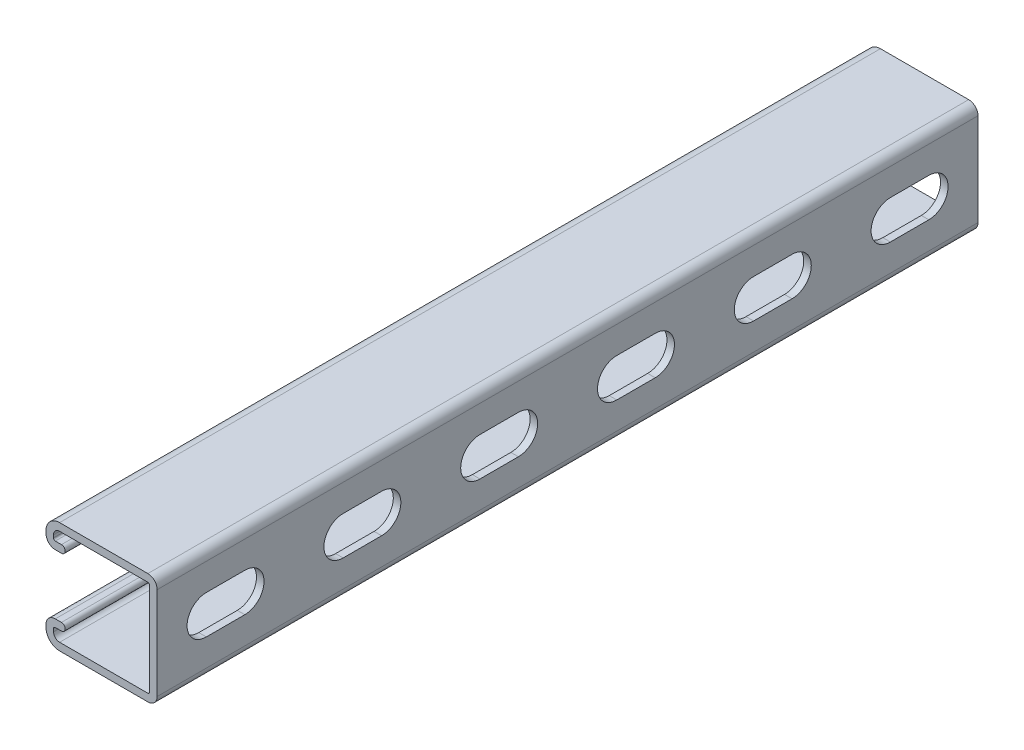
from build123d import *

# Parameters (mm, degrees)
BOSS_EXTRUDE1_DEPTH = 304.8
CUT_EXTRUDE1_DEPTH  = 2.794
LPATTERN1_COUNT     = 6
LPATTERN1_PITCH     = 50.8


with BuildPart() as part:
    # Sketch1 → Boss-Extrude1 (new body)
    with BuildSketch(Plane.XY):
        with BuildLine():
            Line((-36.22675, 20.6375), (-3.46075, 20.6375))
            ThreePointArc((-3.46075, 20.6375), (-1.013630207, 19.623869793), (0, 17.17675))
            Line((0, 17.17675), (0, -17.17675))
            ThreePointArc((0, -17.17675), (-1.013630207, -19.623869793), (-3.46075, -20.6375))
            Line((-3.46075, -20.6375), (-36.22675, -20.6375))
            ThreePointArc((-36.22675, -20.6375), (-39.796401808, -19.158901808), (-41.275, -15.58925))
            Line((-41.275, -15.58925), (-41.275, -14.57325))
            ThreePointArc((-41.275, -14.57325), (-40.261369793, -12.126130207), (-37.81425, -11.1125))
            Line((-37.81425, -11.1125), (-35.5346, -11.1125))
            ThreePointArc((-35.5346, -11.1125), (-34.1376, -12.5095), (-35.5346, -13.9065))
            Line((-35.5346, -13.9065), (-37.81425, -13.9065))
            ThreePointArc((-37.81425, -13.9065), (-38.285713446, -14.101786554), (-38.481, -14.57325))
            Line((-38.481, -14.57325), (-38.481, -15.58925))
            ThreePointArc((-38.481, -15.58925), (-37.820745461, -17.183245461), (-36.22675, -17.8435))
            Line((-36.22675, -17.8435), (-3.46075, -17.8435))
            ThreePointArc((-3.46075, -17.8435), (-2.989286554, -17.648213446), (-2.794, -17.17675))
            Line((-2.794, -17.17675), (-2.794, 17.17675))
            ThreePointArc((-2.794, 17.17675), (-2.989286554, 17.648213446), (-3.46075, 17.8435))
            Line((-3.46075, 17.8435), (-36.22675, 17.8435))
            ThreePointArc((-36.22675, 17.8435), (-37.820745461, 17.183245461), (-38.481, 15.58925))
            Line((-38.481, 15.58925), (-38.481, 14.57325))
            ThreePointArc((-38.481, 14.57325), (-38.285713446, 14.101786554), (-37.81425, 13.9065))
            Line((-37.81425, 13.9065), (-35.5346, 13.9065))
            ThreePointArc((-35.5346, 13.9065), (-34.1376, 12.5095), (-35.5346, 11.1125))
            Line((-35.5346, 11.1125), (-37.81425, 11.1125))
            ThreePointArc((-37.81425, 11.1125), (-40.261369793, 12.126130207), (-41.275, 14.57325))
            Line((-41.275, 14.57325), (-41.275, 15.58925))
            ThreePointArc((-41.275, 15.58925), (-39.796401808, 19.158901808), (-36.22675, 20.6375))
        make_face()
    extrude(amount=-BOSS_EXTRUDE1_DEPTH)

    # Sketch2 → Cut-Extrude1 (cut)
    with BuildSketch(Plane(origin=(0, 0, 0), x_dir=(0, 0, -1), z_dir=(1, 0, 0))):
        with BuildLine():
            Line((18.25625, 7.14375), (32.54375, 7.14375))
            ThreePointArc((32.54375, 7.14375), (39.6875, 0), (32.54375, -7.14375))
            Line((32.54375, -7.14375), (18.25625, -7.14375))
            ThreePointArc((18.25625, -7.14375), (11.1125, 0), (18.25625, 7.14375))
        make_face()
    cut_extrude1 = extrude(amount=-CUT_EXTRUDE1_DEPTH, mode=Mode.SUBTRACT)

    # LPattern1: Cut-Extrude1 ×6
    with Locations(*[(0, 0, -i * LPATTERN1_PITCH) for i in range(1, LPATTERN1_COUNT)]):
        add(cut_extrude1, mode=Mode.SUBTRACT)


solid = part.part
